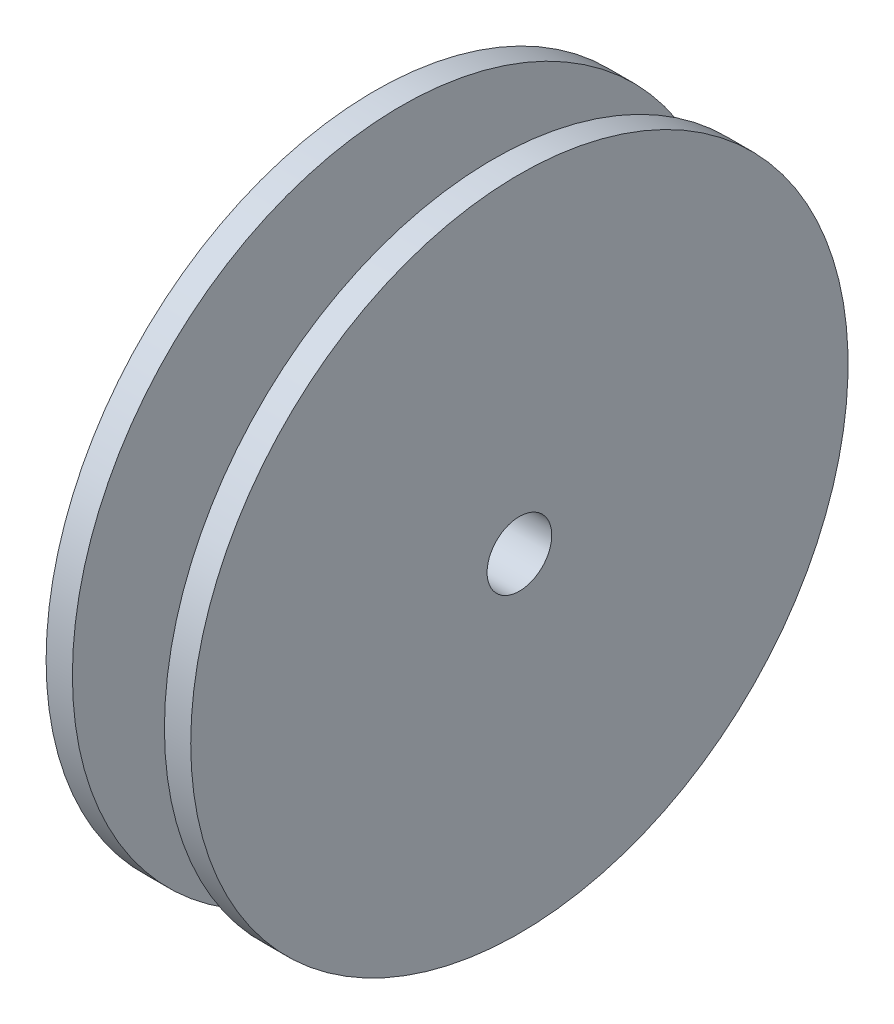
from build123d import *

# Parameters (mm, degrees)
SKETCH2_R          = 3.1242
CUT_EXTRUDE1_DEPTH = 20.05


with BuildPart() as part:
    # Sketch1 → Revolve1 (revolve)
    with BuildSketch(Plane.XY):
        Polygon((0, 0), (19.05, 0), (19.05, 31.75), (16.51, 31.75), (16.51, 19.05), (7.62, 19.05), (7.62, 31.75), (5.08, 31.75), (5.08, 6.35), (0, 6.35), align=None)
    revolve(axis=Axis((0, 0, 0), (1, 0, 0)))

    # Sketch2 → Cut-Extrude1 (cut, through all)
    with BuildSketch(Plane.ZY):
        Circle(SKETCH2_R)
    extrude(amount=-CUT_EXTRUDE1_DEPTH, mode=Mode.SUBTRACT)


solid = part.part
